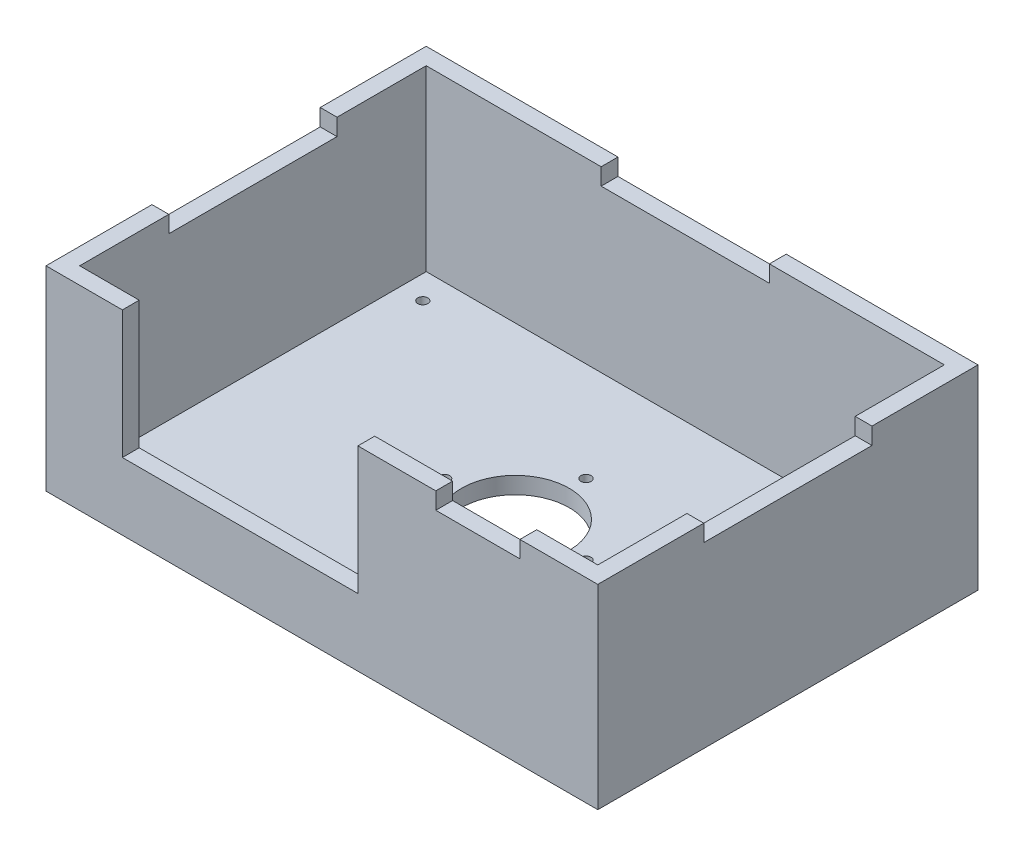
from build123d import *

# Parameters (mm, degrees)
ESQUISSE1_W             = 154
ESQUISSE1_H             = 101
BOSS_EXTRU_1_DEPTH      = 5
ESQUISSE2_R             = 16
ESQUISSE2_R_2           = 1.5
ENL_V_MAT_EXTRU_2_DEPTH = 5
ESQUISSE3_R             = 1.5
ENL_V_MAT_EXTRU_3_DEPTH = 5
ESQUISSE8_W             = 164
ESQUISSE8_H             = 113
ESQUISSE8_W_2           = 154
ESQUISSE8_H_2           = 103
BOSS_EXTRU_3_DEPTH      = 53
BOSS_EXTRU_3_DEPTH_BACK = 5
ESQUISSE9_W             = 154
ESQUISSE9_H             = 2
BOSS_EXTRU_4_DEPTH      = 5
ESQUISSE11_W            = 70
ESQUISSE11_H            = 5
ENL_V_MAT_EXTRU_7_DEPTH = 38
ESQUISSE12_W            = 50
ESQUISSE12_H            = 5
ESQUISSE12_W_2          = 5
ESQUISSE12_H_2          = 50
ENL_V_MAT_EXTRU_8_DEPTH = 5
ESQUISSE13_W            = 25
ESQUISSE13_H            = 5
ENL_V_MAT_EXTRU_9_DEPTH = 5


with BuildPart() as part:
    # Esquisse1 → Boss.-Extru.1 (new body)
    with BuildSketch(Plane(origin=(0, 0, 0), x_dir=(1, 0, 0), z_dir=(0, 1, 0))):
        Rectangle(ESQUISSE1_W, ESQUISSE1_H)
    extrude(amount=BOSS_EXTRU_1_DEPTH)

    # Esquisse2 → Enlèv. mat.-Extru.2 (cut)
    with BuildSketch(Plane(origin=(0, 5, 0), x_dir=(1, 0, 0), z_dir=(0, 1, 0))):
        Circle(ESQUISSE2_R)
        with Locations((0, 21)):
            Circle(ESQUISSE2_R_2)
        with Locations((-21, 0)):
            Circle(ESQUISSE2_R_2)
        with Locations((21, 0)):
            Circle(ESQUISSE2_R_2)
        with Locations((0, -21)):
            Circle(ESQUISSE2_R_2)
    extrude(amount=-ENL_V_MAT_EXTRU_2_DEPTH, mode=Mode.SUBTRACT)

    # Esquisse3 → Enlèv. mat.-Extru.3 (cut)
    with BuildSketch(Plane(origin=(0, 5, 0), x_dir=(1, 0, 0), z_dir=(0, 1, 0))):
        with Locations((70, -45.5)):
            Circle(ESQUISSE3_R)
        with Locations((-70, -45.5)):
            Circle(ESQUISSE3_R)
        with Locations((-70, 42.5)):
            Circle(ESQUISSE3_R)
        with Locations((70, 42.5)):
            Circle(ESQUISSE3_R)
    extrude(amount=-ENL_V_MAT_EXTRU_3_DEPTH, mode=Mode.SUBTRACT)



with BuildPart() as body_2:
    # Esquisse8 → Boss.-Extru.3 (new body, two sides)
    with BuildSketch(Plane(origin=(0, 5, 0), x_dir=(1, 0, 0), z_dir=(0, 1, 0))) as boss_extru_3_sk:
        with Locations((0, -1)):
            Rectangle(ESQUISSE8_W, ESQUISSE8_H)
        with Locations((0, -1)):
            Rectangle(ESQUISSE8_W_2, ESQUISSE8_H_2, mode=Mode.SUBTRACT)
    extrude(amount=BOSS_EXTRU_3_DEPTH)
    extrude(boss_extru_3_sk.sketch, amount=-BOSS_EXTRU_3_DEPTH_BACK)


with BuildPart() as part_1:
    add(part.part)

    add(body_2.part)  # Boss.-Extru.4 merges body 2
    # Esquisse9 → Boss.-Extru.4 (add)
    with BuildSketch(Plane(origin=(0, 0, 0), x_dir=(-1, 0, 0), z_dir=(0, -1, 0))):
        with Locations((0, -51.5)):
            Rectangle(ESQUISSE9_W, ESQUISSE9_H)
    extrude(amount=-BOSS_EXTRU_4_DEPTH)

    # Esquisse11 → Enlèv. mat.-Extru.7 (cut)
    with BuildSketch(Plane(origin=(0, 58, 0), x_dir=(1, 0, 0), z_dir=(0, 1, 0))):
        with Locations((-24.3, -55)):
            Rectangle(ESQUISSE11_W, ESQUISSE11_H)
    extrude(amount=-ENL_V_MAT_EXTRU_7_DEPTH, mode=Mode.SUBTRACT)

    # Esquisse12 → Enlèv. mat.-Extru.8 (cut)
    with BuildSketch(Plane(origin=(0, 58, 0), x_dir=(1, 0, 0), z_dir=(0, 1, 0))):
        with Locations((0, 53)):
            Rectangle(ESQUISSE12_W, ESQUISSE12_H)
        with Locations((79.5, -1)):
            Rectangle(ESQUISSE12_W_2, ESQUISSE12_H_2)
        with Locations((-79.5, -1)):
            Rectangle(ESQUISSE12_W_2, ESQUISSE12_H_2)
    extrude(amount=-ENL_V_MAT_EXTRU_8_DEPTH, mode=Mode.SUBTRACT)

    # Esquisse13 → Enlèv. mat.-Extru.9 (cut)
    with BuildSketch(Plane(origin=(0, 58, 0), x_dir=(1, 0, 0), z_dir=(0, 1, 0))):
        with Locations((46.35, -55)):
            Rectangle(ESQUISSE13_W, ESQUISSE13_H)
    extrude(amount=-ENL_V_MAT_EXTRU_9_DEPTH, mode=Mode.SUBTRACT)


solid = part_1.part
